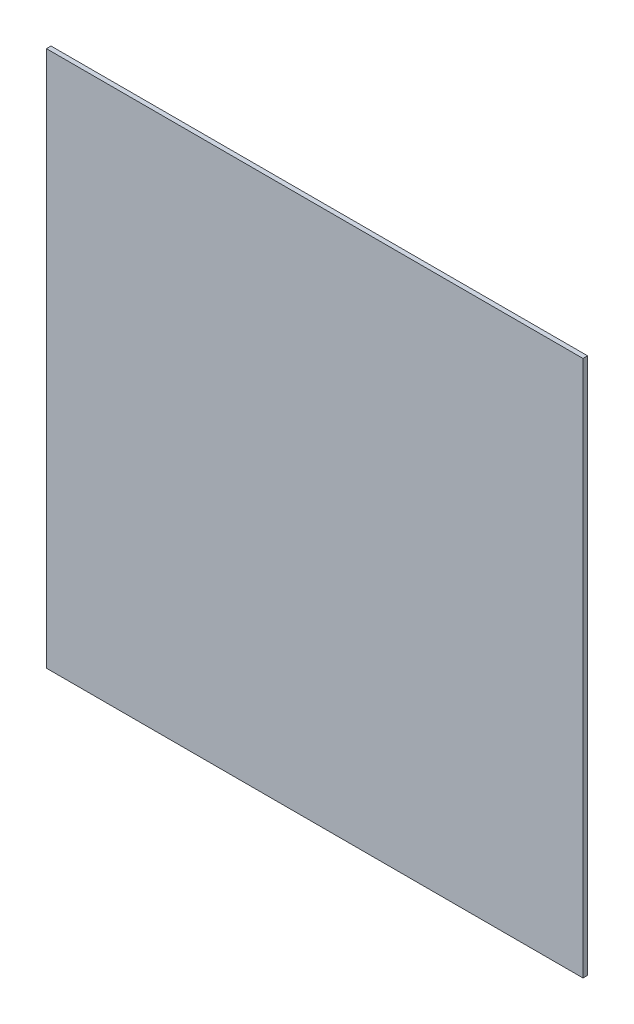
from build123d import *

# Parameters (mm, degrees)
SKETCH1_W           = 1170
SKETCH1_H           = 1170
BOSS_EXTRUDE1_DEPTH = 5


with BuildPart() as part:
    # Sketch1 → Boss-Extrude1 (new body, symmetric)
    with BuildSketch(Plane.XY):
        Rectangle(SKETCH1_W, SKETCH1_H)
    extrude(amount=BOSS_EXTRUDE1_DEPTH, both=True)


solid = part.part
